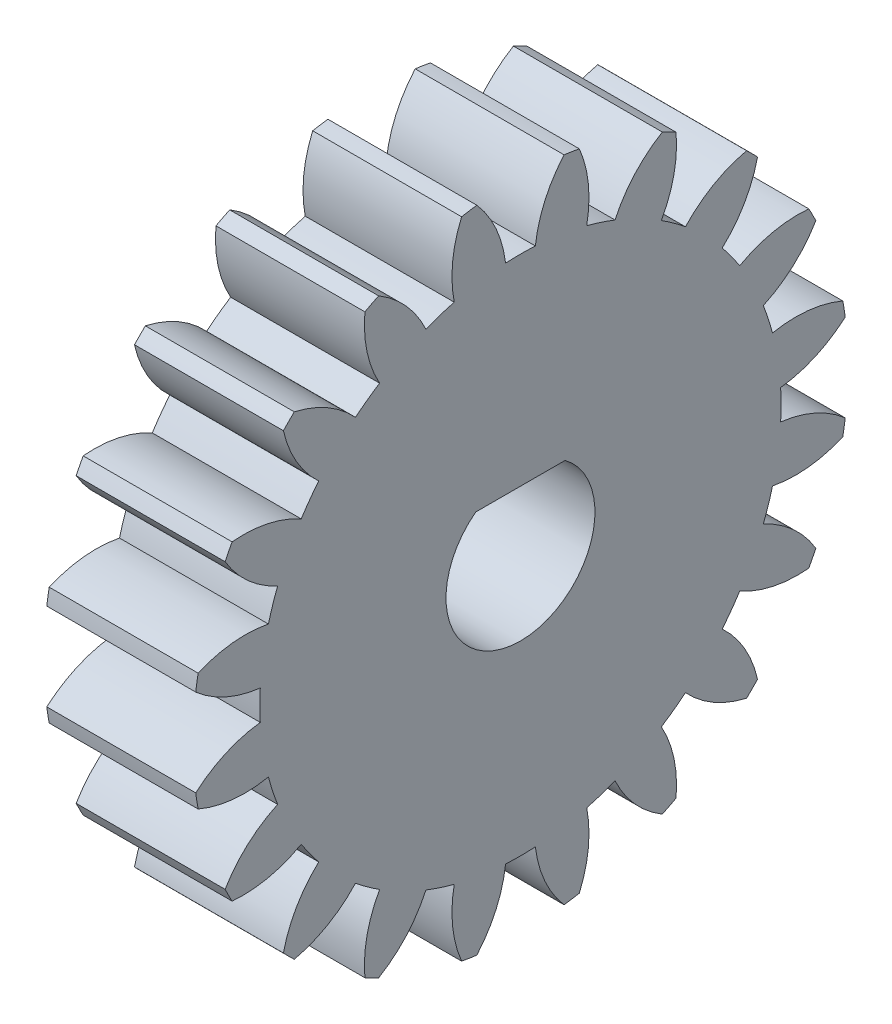
from build123d import *

# Parameters (mm, degrees)
BASPROSKE_W         = 5
BASPROSKE_H         = 11
TOOTHCUT_DEPTH      = 17.340134638
TEETHCUTS_COUNT     = 20
TEETHCUTS_ANGLE     = 342
BORSKE_R            = 1.5
BORE_DEPTH          = 50.0000508
SKETCH1_R           = 2.5
CUT_EXTRUDE1_DEPTH  = 10
SKETCH2_W           = 5.908261021
SKETCH2_H           = 1.397592127
BOSS_EXTRUDE1_DEPTH = 5
SKETCH3_R           = 2.5
CUT_EXTRUDE2_DEPTH  = 10
SKETCH4_W           = 5.744521792
SKETCH4_H           = 0.916677302
BOSS_EXTRUDE2_DEPTH = 5


with BuildPart() as part:
    # BasProSke → Base-Revolve (revolve)
    with BuildSketch(Plane(origin=(0, 0, 0), x_dir=(1, 0, 0), z_dir=(0, 1, 0)), mode=Mode.PRIVATE) as base_revolve_sk:
        with Locations((2.5, 5.5)):
            Rectangle(BASPROSKE_W, BASPROSKE_H)
    revolve(base_revolve_sk.sketch.rotate(Axis((-10, 0, 0), (1, 0, 0)), 180), axis=Axis((-10, 0, 0), (1, 0, 0)))

    # TooCutSke → ToothCut (cut, through all)
    with BuildSketch(Plane(origin=(0, 0, 0), x_dir=(0, 0, -1), z_dir=(1, 0, 0))):
        with BuildLine():
            ThreePointArc((0.499924007, 8.734705318), (0, 8.749), (-0.499924007, 8.734705318))
            ThreePointArc((-0.499924007, 8.734705318), (-0.824302243, 9.905497836), (-1.485192705, 10.924909509))
            ThreePointArc((-1.485192705, 10.924909509), (0, 11.0254), (1.485192705, 10.924909509))
            ThreePointArc((1.485192705, 10.924909509), (0.824302243, 9.905497836), (0.499924007, 8.734705318))
        make_face()
    toothcut = extrude(amount=TOOTHCUT_DEPTH, mode=Mode.SUBTRACT)

    # TeethCuts: ToothCut ×20 about axis
    teethcuts_axis = Axis((-10, 0, 0), (1, 0, 0))
    for i in range(1, TEETHCUTS_COUNT):
        add(toothcut.rotate(teethcuts_axis, i * TEETHCUTS_ANGLE / (TEETHCUTS_COUNT - 1)), mode=Mode.SUBTRACT)

    # BorSke → Bore (cut, symmetric)
    with BuildSketch(Plane(origin=(0, 0, 0), x_dir=(0, 0, -1), z_dir=(1, 0, 0))):
        with Locations(Location((0, 0, 0), (0, 0, 180))):
            Circle(BORSKE_R)
    extrude(amount=BORE_DEPTH, both=True, mode=Mode.SUBTRACT)

    # Sketch1 → Cut-Extrude1 (cut)
    with BuildSketch(Plane(origin=(5, 0, 0), x_dir=(0, 0, -1), z_dir=(1, 0, 0))):
        Circle(SKETCH1_R)
    extrude(amount=-CUT_EXTRUDE1_DEPTH, mode=Mode.SUBTRACT)

    # Sketch2 → Boss-Extrude1 (add)
    with BuildSketch(Plane(origin=(5, 0, 0), x_dir=(0, 0, -1), z_dir=(1, 0, 0))):
        with Locations((-0.183749745, 2.198796064)):
            Rectangle(SKETCH2_W, SKETCH2_H)
    extrude(amount=-BOSS_EXTRUDE1_DEPTH)

    # Sketch3 → Cut-Extrude2 (cut)
    with BuildSketch(Plane.ZY):
        with Locations(Location((0, 0, 0), (0, 0, 180))):
            Circle(SKETCH3_R)
    extrude(amount=-CUT_EXTRUDE2_DEPTH, mode=Mode.SUBTRACT)

    # Sketch4 → Boss-Extrude2 (add, through all)
    with BuildSketch(Plane.ZY):
        with Locations((0.562607804, 2.458338651)):
            Rectangle(SKETCH4_W, SKETCH4_H)
    extrude(amount=-BOSS_EXTRUDE2_DEPTH)


solid = part.part
